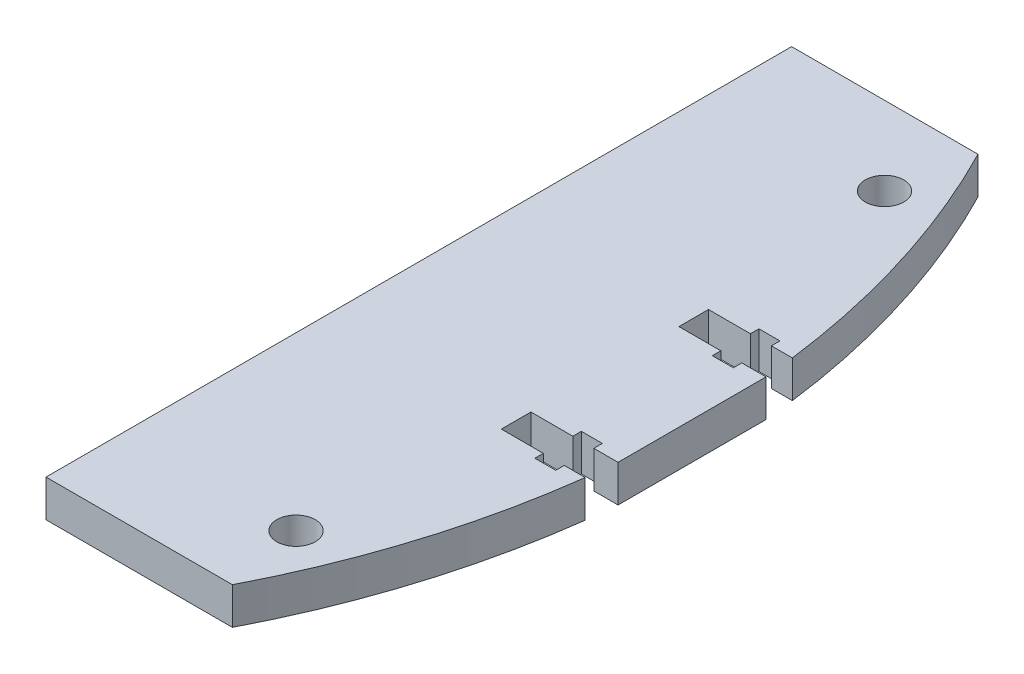
from build123d import *

# Parameters (mm, degrees)
SKETCH1_R           = 1.65
BOSS_EXTRUDE1_DEPTH = 3.175


with BuildPart() as part:
    # Sketch1 → Boss-Extrude1 (new body)
    with BuildSketch(Plane(origin=(0, 0, 0), x_dir=(1, 0, 0), z_dir=(0, 1, 0))):
        with BuildLine():
            Line((62.257529665, 32), (46.257529665, 32))
            Line((46.257529665, 32), (46.257529665, -32))
            Line((46.257529665, -32), (62.257529665, -32))
            ThreePointArc((62.257529665, -32), (66.851547843, -20.757421588), (69.43319019, -8.89))
            Line((69.43319019, -8.89), (67.63319019, -8.89))
            Line((67.63319019, -8.89), (67.63319019, -9.62))
            Line((67.63319019, -9.62), (65.83319019, -9.62))
            Line((65.83319019, -9.62), (65.83319019, -8.89))
            Line((65.83319019, -8.89), (62.23319019, -8.89))
            Line((62.23319019, -8.89), (62.23319019, -6.35))
            Line((62.23319019, -6.35), (65.83319019, -6.35))
            Line((65.83319019, -6.35), (65.83319019, -5.62))
            Line((65.83319019, -5.62), (67.63319019, -5.62))
            Line((67.63319019, -5.62), (67.63319019, -6.35))
            Line((67.63319019, -6.35), (69.711387162, -6.35))
            Line((69.711387162, -6.35), (69.711387162, 6.35))
            Line((69.711387162, 6.35), (67.63319019, 6.35))
            Line((67.63319019, 6.35), (67.63319019, 5.62))
            Line((67.63319019, 5.62), (65.83319019, 5.62))
            Line((65.83319019, 5.62), (65.83319019, 6.35))
            Line((65.83319019, 6.35), (62.23319019, 6.35))
            Line((62.23319019, 6.35), (62.23319019, 8.89))
            Line((62.23319019, 8.89), (65.83319019, 8.89))
            Line((65.83319019, 8.89), (65.83319019, 9.62))
            Line((65.83319019, 9.62), (67.63319019, 9.62))
            Line((67.63319019, 9.62), (67.63319019, 8.89))
            Line((67.63319019, 8.89), (69.43319019, 8.89))
            ThreePointArc((69.43319019, 8.89), (66.851547843, 20.757421588), (62.257529665, 32))
        make_face()
        with Locations((60.976049146, -25.257106536)):
            Circle(SKETCH1_R, mode=Mode.SUBTRACT)
        with Locations((60.976049146, 25.257106536)):
            Circle(SKETCH1_R, mode=Mode.SUBTRACT)
    extrude(amount=BOSS_EXTRUDE1_DEPTH)


solid = part.part
